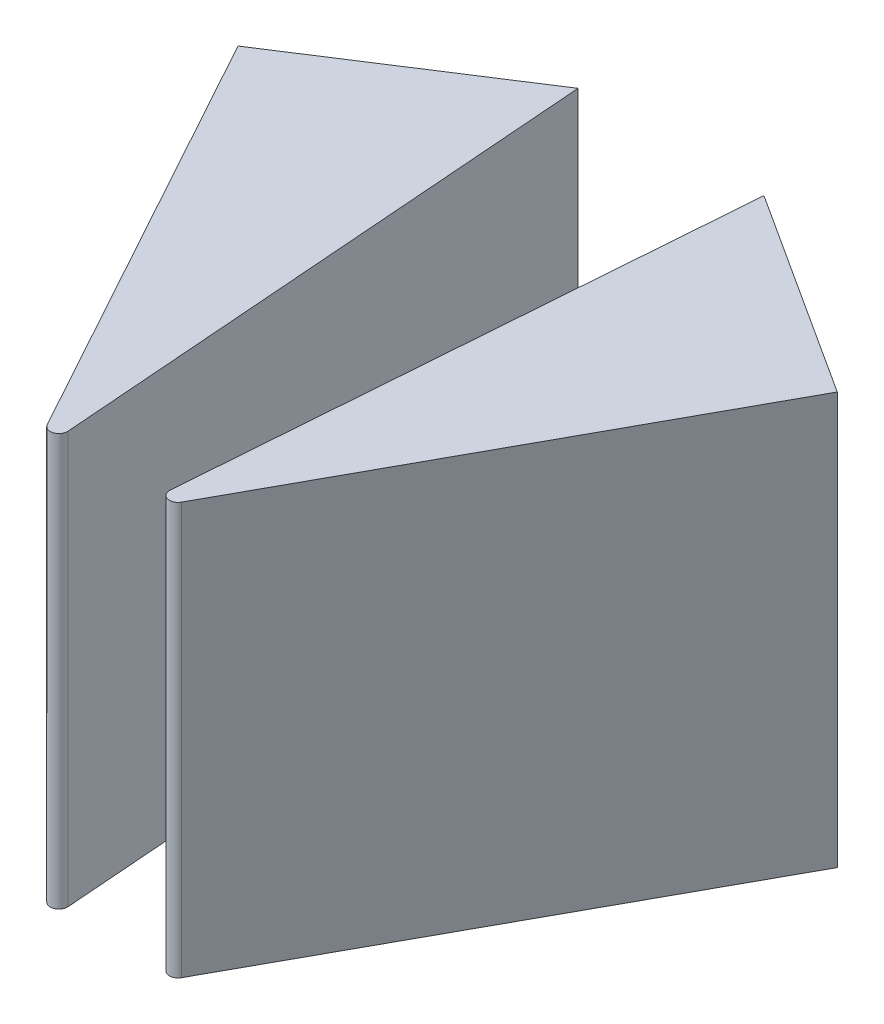
from build123d import *

# Parameters (mm, degrees)
BOSS_EXTRUDE1_DEPTH = 60


with BuildPart() as part:
    # Sketch2 → Boss-Extrude1 (new body)
    with BuildSketch(Plane(origin=(0, 0, 0), x_dir=(1, 0, 0), z_dir=(0, 1, 0))):
        with BuildLine():
            Line((13.540624936, 3.623045913), (7.436989183, -76.767941202))
            ThreePointArc((7.436989183, -76.767941202), (8.327108076, -78.060720686), (9.778994631, -77.464385319))
            Line((9.778994631, -77.464385319), (43.647777878, -15.806500364))
            Line((43.647777878, -15.806500364), (13.540624936, 3.623045913))
        make_face()
    extrude(amount=BOSS_EXTRUDE1_DEPTH)


with BuildPart() as body_2:
    # Mirror2: mirrored copy
    add(part.part.mirror(Plane(origin=(0, 0, 0), x_dir=(0, 0, 1), z_dir=(1, 0, 0))))


solid = Compound([part.part, body_2.part])
